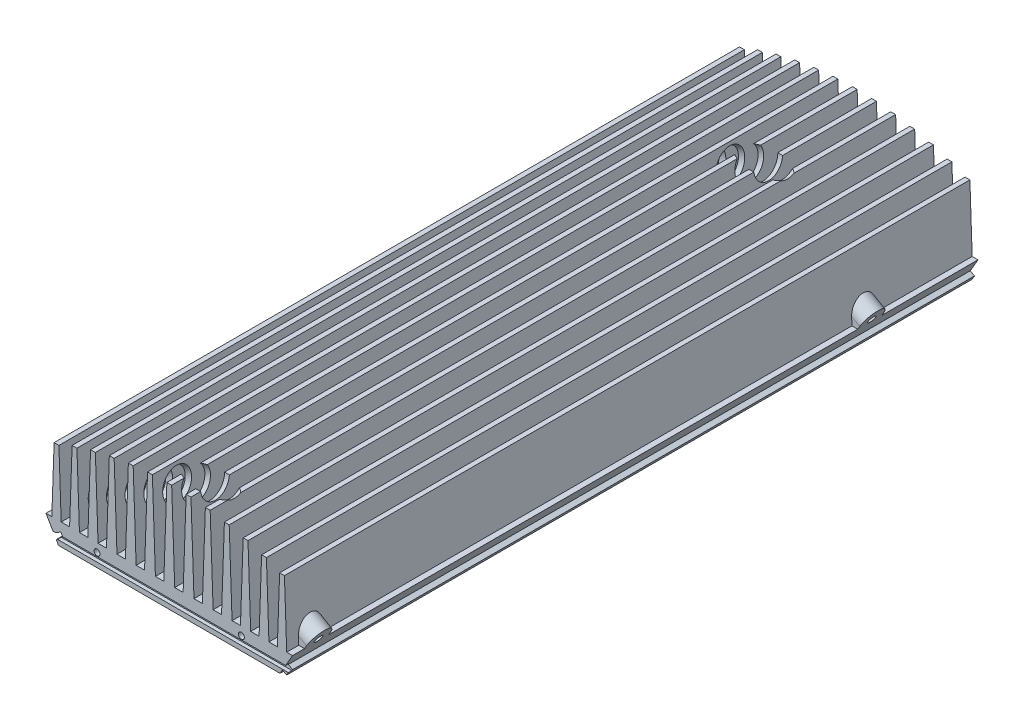
from build123d import *

# Parameters (mm, degrees)
RESSALTO_EXTRUS_O1_DEPTH   = 285
CORTE_EXTRUS_O1_DEPTH      = 286
RESSALTO_EXTRUS_O3_DEPTH   = 285
ESBO_O13_W                 = 1.5
ESBO_O13_H                 = 2
CORTE_EXTRUS_O7_DEPTH      = 52.25
CORTE_EXTRUS_O7_DEPTH_BACK = 52.25
RESSALTO_EXTRUS_O5_DEPTH   = 10
ESBO_O5_R                  = 1.25
CORTE_EXTRUS_O3_DEPTH      = 10
ESBO_O6_W                  = 10
ESBO_O6_H                  = 6.190700041
RESSALTO_EXTRUS_O4_DEPTH   = 11
ESBO_O7_R                  = 2.25
CORTE_EXTRUS_O4_DEPTH      = 12
ESBO_O9_R                  = 1.65
CORTE_EXTRUS_O5_DEPTH      = 10
RESSALTO_EXTRUS_O6_DEPTH   = 15
ESBO_O12_R                 = 2.5
CORTE_EXTRUS_O8_DEPTH      = 20
CORTE_EXTRUS_O9_START      = -11
ESBO_O14_R                 = 6
CORTE_EXTRUS_O9_DEPTH      = 100
PADR_O_LINEAR1_COUNT       = 2
PADR_O_LINEAR1_PITCH       = 230
ESBO_O15_R                 = 1.65
ESBO_O15_R_2               = 1.25
CORTE_EXTRUS_O10_DEPTH     = 8


with BuildPart() as part:
    # Esboço1 → Ressalto-extrusão1 (new body)
    with BuildSketch(Plane.XY):
        Polygon((-46.053847577, 79.767603888), (-51.25, 88.767603888), (-48.82913331, 88.767603888), (-47.882520117, 115.87505904), (-45.882520117, 115.87505904), (-44.935906924, 88.767603888), (-41.435906924, 88.767603888), (-40.393073045, 118.630458973), (-38.393073045, 118.630458973), (-37.350239166, 88.767603888), (-33.850239166, 88.767603888), (-32.727930438, 120.906320886), (-30.727930438, 120.906320886), (-29.60562171, 88.767603888), (-26.10562171, 88.767603888), (-24.921032923, 122.689788425), (-22.921032923, 122.689788425), (-21.736444137, 88.767603888), (-18.236444137, 88.767603888), (-17.007119627, 123.970851902), (-15.007119627, 123.970851902), (-13.777795118, 88.767603888), (-10.277795118, 88.767603888), (-9.021529135, 124.742354757), (-7.021529135, 124.742354757), (-5.765263153, 88.767603888), (-2.265263153, 88.767603888), (-1, 125), (1, 125), (2.265263153, 88.767603888), (5.765263153, 88.767603888), (7.021529135, 124.742354757), (9.021529135, 124.742354757), (10.277795118, 88.767603888), (13.777795118, 88.767603888), (15.007119627, 123.970851902), (17.007119627, 123.970851902), (18.236444137, 88.767603888), (21.736444137, 88.767603888), (22.921032923, 122.689788425), (24.921032923, 122.689788425), (26.10562171, 88.767603888), (29.60562171, 88.767603888), (30.727930438, 120.906320886), (32.727930438, 120.906320886), (33.850239166, 88.767603888), (37.350239166, 88.767603888), (38.393073045, 118.630458973), (40.393073045, 118.630458973), (41.435906924, 88.767603888), (44.935906924, 88.767603888), (45.882520117, 115.87505904), (47.882520117, 115.87505904), (48.82913331, 88.767603888), (51.25, 88.767603888), (46.053847577, 79.767603888), align=None)
    extrude(amount=RESSALTO_EXTRUS_O1_DEPTH)

    # Esboço2 → Corte-extrusão1 (cut, through all)
    with BuildSketch(Plane.XY.offset(285)):
        Polygon((-47.003847577, 81.413052155), (-43.972758664, 83.163052155), (-45.072758664, 85.068308043), (-48.103847577, 83.318308043), align=None)
    extrude(amount=-CORTE_EXTRUS_O1_DEPTH, mode=Mode.SUBTRACT)


with BuildPart() as body_2:
    # Esboço3 → Ressalto-extrusão3 (new body)
    with BuildSketch(Plane.XY.offset(285)):
        Polygon((47.053847577, 81.499654695), (48.053847577, 83.231705503), (49.785898385, 82.231705503), (48.785898385, 80.499654695), align=None)
    extrude(amount=-RESSALTO_EXTRUS_O3_DEPTH)


with BuildPart() as corte_extrus_o7_tool:
    # Esboço13 → Corte-extrusão7 (new body, two sides)
    with BuildSketch(Plane(origin=(0, 0, 0), x_dir=(0, 0, -1), z_dir=(1, 0, 0))) as corte_extrus_o7_sk:
        with Locations((-284.25, 82.767603888)):
            Rectangle(ESBO_O13_W, ESBO_O13_H)
    extrude(amount=CORTE_EXTRUS_O7_DEPTH)
    extrude(corte_extrus_o7_sk.sketch, amount=-CORTE_EXTRUS_O7_DEPTH_BACK)


with BuildPart() as part_1:
    add(part.part)

    # Corte-extrusão7: cut by corte_extrus_o7_tool
    add(corte_extrus_o7_tool.part, mode=Mode.SUBTRACT)



with BuildPart() as body_2_1:
    add(body_2.part)

    # Corte-extrusão7: cut by corte_extrus_o7_tool
    add(corte_extrus_o7_tool.part, mode=Mode.SUBTRACT)


with BuildPart() as part_2:
    add(part_1.part)

    add(body_2_1.part)  # Ressalto-extrusão5 merges body 2
    # Esboço8 → Ressalto-extrusão5 (add)
    with BuildSketch(Plane(origin=(0, 0, 0), x_dir=(0, 0, -1), z_dir=(0.866025404, -0.5, 0))):
        with BuildLine():
            Line((-280, 104.107695155), (-280, 96.107695155))
            Line((-280, 96.107695155), (-270, 96.107695155))
            Line((-270, 96.107695155), (-270, 104.107695155))
            ThreePointArc((-270, 104.107695155), (-275, 109.107695155), (-280, 104.107695155))
        make_face()
    ressalto_extrus_o5 = extrude(amount=-RESSALTO_EXTRUS_O5_DEPTH)

    # Esboço5 → Corte-extrusão3 (cut)
    with BuildSketch(Plane.XY.offset(285)):
        with Locations((-30, 85.267603888)):
            Circle(ESBO_O5_R)
        with Locations((30, 85.267603888)):
            Circle(ESBO_O5_R)
    extrude(amount=-CORTE_EXTRUS_O3_DEPTH, mode=Mode.SUBTRACT)

    # Esboço6 → Ressalto-extrusão4 (add)
    with BuildSketch(Plane(origin=(0, 0, 0), x_dir=(0, 0, 1), z_dir=(-0.866025404, -0.5, 0))):
        with BuildLine():
            Line((280, 102.5), (280, 104.207693629))
            ThreePointArc((280, 104.207693629), (275, 109.207695155), (270, 104.207693629))
            Line((270, 104.207693629), (270, 102.5))
            Line((270, 102.5), (280, 102.5))
        make_face()
        with Locations((275, 99.404649979)):
            Rectangle(ESBO_O6_W, ESBO_O6_H)
    ressalto_extrus_o4 = extrude(amount=-RESSALTO_EXTRUS_O4_DEPTH)

    # Esboço7 → Corte-extrusão4 (cut)
    with BuildSketch(Plane(origin=(0, 0, 0), x_dir=(0, 0, 1), z_dir=(-0.866025404, -0.5, 0))):
        with Locations((275, 104.207695155)):
            Circle(ESBO_O7_R)
    corte_extrus_o4 = extrude(amount=-CORTE_EXTRUS_O4_DEPTH, mode=Mode.SUBTRACT)

    # Esboço9 → Corte-extrusão5 (cut)
    with BuildSketch(Plane(origin=(0, 0, 0), x_dir=(0, 0, -1), z_dir=(0.866025404, -0.5, 0))):
        with Locations((-275, 104.107695155)):
            Circle(ESBO_O9_R)
    corte_extrus_o5 = extrude(amount=-CORTE_EXTRUS_O5_DEPTH, mode=Mode.SUBTRACT)

    # Esboço10 → Ressalto-extrusão6 (add)
    with BuildSketch(Plane(origin=(0, 0, 0), x_dir=(-1, 0, 0), z_dir=(0, 0, -1))):
        Polygon((5.765263153, 88.767603888), (6.680885729, 114.987603888), (1.349640577, 114.987603888), (2.265263153, 88.767603888), align=None)
        Polygon((-2.265263153, 88.767603888), (-1.349640577, 114.987603888), (-6.680885729, 114.987603888), (-5.765263153, 88.767603888), align=None)
    extrude(amount=-RESSALTO_EXTRUS_O6_DEPTH)

    # Esboço12 → Corte-extrusão8 (cut)
    with BuildSketch(Plane(origin=(0, 0, 0), x_dir=(-1, 0, 0), z_dir=(0, 0, -1))):
        with Locations((0, 104.999999962)):
            Circle(ESBO_O12_R)
    extrude(amount=-CORTE_EXTRUS_O8_DEPTH, mode=Mode.SUBTRACT)

    # Esboço14 → Corte-extrusão9 (cut)
    with BuildSketch(Plane(origin=(0, 0, 0), x_dir=(0, 0, 1), z_dir=(-0.866025404, -0.5, 0)).offset(CORTE_EXTRUS_O9_START)):
        with Locations((275, 104.207695155)):
            Circle(ESBO_O14_R)
    corte_extrus_o9 = extrude(amount=-CORTE_EXTRUS_O9_DEPTH, mode=Mode.SUBTRACT)

    # Padrão linear1: Ressalto-extrusão5, Ressalto-extrusão4, Corte-extrusão4, Corte-extrusão5, Corte-extrusão9 ×2
    with Locations(*[(0, 0, -i * PADR_O_LINEAR1_PITCH) for i in range(1, PADR_O_LINEAR1_COUNT)]):
        add(ressalto_extrus_o5)
        add(ressalto_extrus_o4)
        add(corte_extrus_o4, mode=Mode.SUBTRACT)
        add(corte_extrus_o5, mode=Mode.SUBTRACT)
        add(corte_extrus_o9, mode=Mode.SUBTRACT)

    # Esboço15 → Corte-extrusão10 (cut)
    with BuildSketch(Plane.XZ.offset(-79.767603888)):
        with Locations((36.5, 246.65)):
            Circle(ESBO_O15_R)
        with Locations((-36.5, 246.65)):
            Circle(ESBO_O15_R)
        with Locations((38.145, 142.066)):
            Circle(ESBO_O15_R)
        with Locations((32.5, 12.65)):
            Circle(ESBO_O15_R)
        with Locations((-38.5, 26.15)):
            Circle(ESBO_O15_R)
        with Locations((-15.83, 8.335)):
            Circle(ESBO_O15_R_2)
        with Locations((-15.449, 26.242)):
            Circle(ESBO_O15_R_2)
        with Locations((25.572, 49.15)):
            Circle(ESBO_O15_R_2)
        with Locations((21.762, 76.661)):
            Circle(ESBO_O15_R_2)
        with Locations((-25.863, 97.743)):
            Circle(ESBO_O15_R_2)
        with Locations((-22.307, 180.42)):
            Circle(ESBO_O15_R_2)
        with Locations((27.096, 173.943)):
            Circle(ESBO_O15_R_2)
        with Locations((21.254, 234.65)):
            Circle(ESBO_O15_R_2)
        with Locations((17.500001526, 217.649999573)):
            Circle(ESBO_O15_R_2)
        with Locations((17.500001526, 197.649999573)):
            Circle(ESBO_O15_R_2)
        with Locations((17.500001526, 177.649999573)):
            Circle(ESBO_O15_R_2)
        with Locations((17.5, 157.65)):
            Circle(ESBO_O15_R_2)
        with Locations((-17.499998474, 127.649991943)):
            Circle(ESBO_O15_R_2)
        with Locations((-17.499998474, 107.650007202)):
            Circle(ESBO_O15_R_2)
        with Locations((-17.499998474, 87.650007202)):
            Circle(ESBO_O15_R_2)
        with Locations((-17.499998474, 67.649991943)):
            Circle(ESBO_O15_R_2)
    extrude(amount=-CORTE_EXTRUS_O10_DEPTH, mode=Mode.SUBTRACT)


solid = part_2.part
